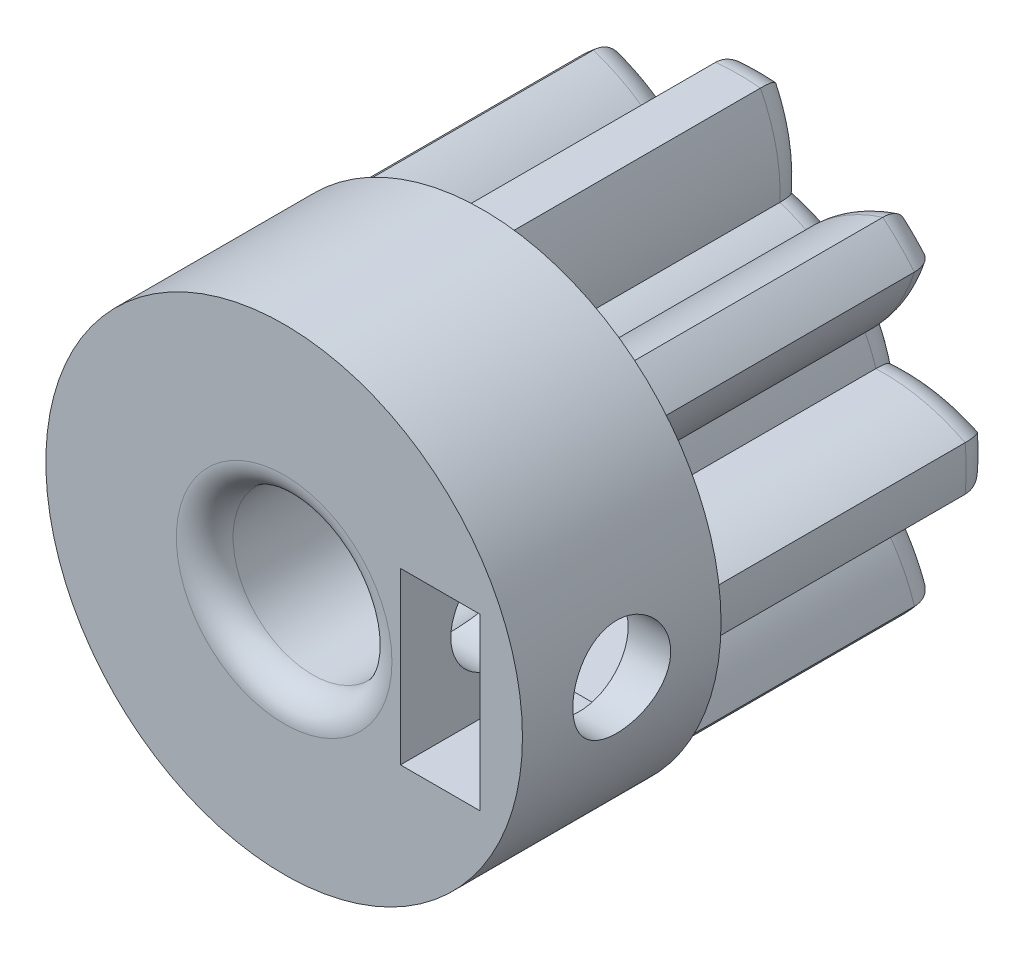
from build123d import *

# Parameters (mm, degrees)
CROQUIS3_R              = 8.4
SALIENTE_EXTRUIR2_DEPTH = 7
SALIENTE_EXTRUIR3_DEPTH = 10
REDONDEO1_R             = 1
CROQUIS5_R              = 2.8
CORTAR_EXTRUIR1_DEPTH   = 18.0000001
REDONDEO2_R             = 1
CROQUIS6_W              = 2.8
CROQUIS6_H              = 6
CORTAR_EXTRUIR2_DEPTH   = 5.2898
CORTAR_EXTRUIR3_DEPTH   = 2.8
CROQUIS8_R              = 1.725
CORTAR_EXTRUIR4_DEPTH   = 7.2898


with BuildPart() as part:
    # Croquis3 → Saliente-Extruir2 (new body)
    with BuildSketch(Plane.XY):
        Circle(CROQUIS3_R)
    extrude(amount=-SALIENTE_EXTRUIR2_DEPTH)

    # Croquis4 → Saliente-Extruir3 (add)
    with BuildSketch(Plane(origin=(0, 0, -7), x_dir=(-1, 0, 0), z_dir=(0, 0, -1))):
        with BuildLine():
            ThreePointArc((0.788391835, 8.004473084), (1.337847, 6.475514817), (1.473191835, 4.856473084))
            ThreePointArc((1.473191835, 4.856473084), (1.942118419, 4.688688627), (2.392341114, 4.475748987))
            ThreePointArc((2.392341114, 4.475748987), (3.632631327, 5.525267682), (5.102539985, 6.21749441))
            ThreePointArc((5.102539985, 6.21749441), (5.687384749, 5.687384749), (6.21749441, 5.102539985))
            ThreePointArc((6.21749441, 5.102539985), (5.524881125, 3.632879754), (4.475748987, 2.392341114))
            ThreePointArc((4.475748987, 2.392341114), (4.688688627, 1.942118419), (4.856473084, 1.473191835))
            ThreePointArc((4.856473084, 1.473191835), (6.475612491, 1.338296), (8.004473084, 0.788391835))
            ThreePointArc((8.004473084, 0.788391835), (8.043176647, 0), (8.004473084, -0.788391835))
            ThreePointArc((8.004473084, -0.788391835), (6.475514817, -1.337847), (4.856473084, -1.473191835))
            ThreePointArc((4.856473084, -1.473191835), (4.688688627, -1.942118419), (4.475748987, -2.392341114))
            ThreePointArc((4.475748987, -2.392341114), (5.525267682, -3.632631327), (6.21749441, -5.102539985))
            ThreePointArc((6.21749441, -5.102539985), (5.687384749, -5.687384749), (5.102539985, -6.21749441))
            ThreePointArc((5.102539985, -6.21749441), (3.632879754, -5.524881125), (2.392341114, -4.475748987))
            ThreePointArc((2.392341114, -4.475748987), (1.942118419, -4.688688627), (1.473191835, -4.856473084))
            ThreePointArc((1.473191835, -4.856473084), (1.338296, -6.475612491), (0.788391835, -8.004473084))
            ThreePointArc((0.788391835, -8.004473084), (0, -8.043176647), (-0.788391835, -8.004473084))
            ThreePointArc((-0.788391835, -8.004473084), (-1.337847, -6.475514817), (-1.473191835, -4.856473084))
            ThreePointArc((-1.473191835, -4.856473084), (-1.942118419, -4.688688627), (-2.392341114, -4.475748987))
            ThreePointArc((-2.392341114, -4.475748987), (-3.632631327, -5.525267682), (-5.102539985, -6.21749441))
            ThreePointArc((-5.102539985, -6.21749441), (-5.687384749, -5.687384749), (-6.21749441, -5.102539985))
            ThreePointArc((-6.21749441, -5.102539985), (-5.524881125, -3.632879754), (-4.475748987, -2.392341114))
            ThreePointArc((-4.475748987, -2.392341114), (-4.688688627, -1.942118419), (-4.856473084, -1.473191835))
            ThreePointArc((-4.856473084, -1.473191835), (-6.475612491, -1.338296), (-8.004473084, -0.788391835))
            ThreePointArc((-8.004473084, -0.788391835), (-8.043176647, 0), (-8.004473084, 0.788391835))
            ThreePointArc((-8.004473084, 0.788391835), (-6.475514817, 1.337847), (-4.856473084, 1.473191835))
            ThreePointArc((-4.856473084, 1.473191835), (-4.688688627, 1.942118419), (-4.475748987, 2.392341114))
            ThreePointArc((-4.475748987, 2.392341114), (-5.525267682, 3.632631327), (-6.21749441, 5.102539985))
            ThreePointArc((-6.21749441, 5.102539985), (-5.687384749, 5.687384749), (-5.102539985, 6.21749441))
            ThreePointArc((-5.102539985, 6.21749441), (-3.632879754, 5.524881125), (-2.392341114, 4.475748987))
            ThreePointArc((-2.392341114, 4.475748987), (-1.942118419, 4.688688627), (-1.473191835, 4.856473084))
            ThreePointArc((-1.473191835, 4.856473084), (-1.338296, 6.475612491), (-0.788391835, 8.004473084))
            ThreePointArc((-0.788391835, 8.004473084), (0, 8.043176647), (0.788391835, 8.004473084))
        make_face()
    extrude(amount=SALIENTE_EXTRUIR3_DEPTH)

    # Redondeo1
    redondeo1_edges = [part.edges().sort_by_distance(p)[0] for p in [
        (0, 8.043176647, -17),
        (1.338296, 6.475612491, -17),
        (1.942118419, 4.688688627, -17),
        (3.632879754, 5.524881125, -17),
        (5.687384749, 5.687384749, -17),
        (5.525267682, 3.632631327, -17),
        (4.688688627, 1.942118419, -17),
        (6.475514817, 1.337847, -17),
        (8.043176647, 0, -17),
        (6.475612491, -1.338296, -17),
        (4.688688627, -1.942118419, -17),
        (5.524881125, -3.632879754, -17),
        (5.687384749, -5.687384749, -17),
        (3.632631327, -5.525267682, -17),
        (1.942118419, -4.688688627, -17),
        (1.337847, -6.475514817, -17),
        (0, -8.043176647, -17),
        (-1.338296, -6.475612491, -17),
        (-1.942118419, -4.688688627, -17),
        (-3.632879754, -5.524881125, -17),
        (-5.687384749, -5.687384749, -17),
        (-5.525267682, -3.632631327, -17),
        (-4.688688627, -1.942118419, -17),
        (-6.475514817, -1.337847, -17),
        (-8.043176647, 0, -17),
        (-6.475612491, 1.338296, -17),
        (-4.688688627, 1.942118419, -17),
        (-5.524881125, 3.632879754, -17),
        (-5.687384749, 5.687384749, -17),
        (-3.632631327, 5.525267682, -17),
        (-1.942118419, 4.688688627, -17),
        (-1.337847, 6.475514817, -17),
    ]]
    fillet(redondeo1_edges, radius=REDONDEO1_R)

    # Croquis5 → Cortar-Extruir1 (cut, through all)
    with BuildSketch(Plane.XY):
        Circle(CROQUIS5_R)
    extrude(amount=-CORTAR_EXTRUIR1_DEPTH, mode=Mode.SUBTRACT)

    # Redondeo2
    redondeo2_edges = [part.edges().sort_by_distance(p)[0] for p in [
        (-2.8, 0, 0),
    ]]
    fillet(redondeo2_edges, radius=REDONDEO2_R)

    # Croquis6 → Cortar-Extruir2 (cut)
    with BuildSketch(Plane.XY):
        with Locations((5.5, 0)):
            Rectangle(CROQUIS6_W, CROQUIS6_H)
    extrude(amount=-CORTAR_EXTRUIR2_DEPTH, mode=Mode.SUBTRACT)

    # Croquis7 → Cortar-Extruir3 (cut)
    with BuildSketch(Plane(origin=(4.1, 0, 0), x_dir=(0, 0, -1), z_dir=(1, 0, 0))):
        Polygon((5.2898, 3), (7.0796, 0), (5.2898, -3), align=None)
    extrude(amount=CORTAR_EXTRUIR3_DEPTH, mode=Mode.SUBTRACT)

    # Croquis8 → Cortar-Extruir4 (cut)
    with BuildSketch(Plane(origin=(8.4, 0, 0), x_dir=(0, 0, -1), z_dir=(1, 0, 0))):
        with Locations((3.5, 0)):
            Circle(CROQUIS8_R)
    extrude(amount=-CORTAR_EXTRUIR4_DEPTH, mode=Mode.SUBTRACT)


solid = part.part
